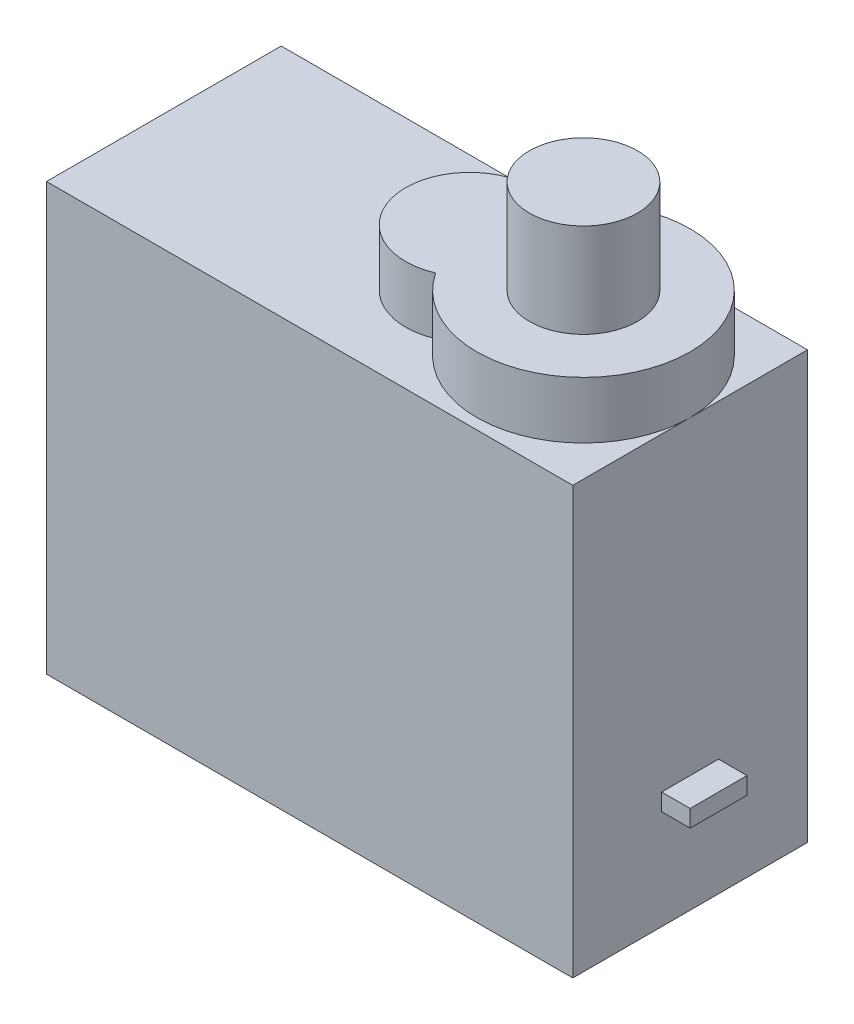
from build123d import *

# Parameters (mm, degrees)
SKETCH_1_W      = 18.5
SKETCH_1_H      = 8.25
EXTRUDE_1_DEPTH = 15
SKETCH_2_R      = 3.75
EXTRUDE_2_DEPTH = 2
SKETCH_3_R      = 2.25
EXTRUDE_3_DEPTH = 2
SKETCH_4_R      = 1.9
EXTRUDE_4_DEPTH = 3.3
SKETCH_5_W      = 2
SKETCH_5_H      = 0.6
EXTRUDE_5_DEPTH = 1


with BuildPart() as part:
    # 草图1 → 凸台-拉伸1 (new body)
    with BuildSketch(Plane(origin=(0, 0, 0), x_dir=(1, 0, 0), z_dir=(0, 1, 0))):
        Rectangle(SKETCH_1_W, SKETCH_1_H)
    extrude(amount=EXTRUDE_1_DEPTH)

    # 草图2 → 凸台-拉伸2 (add)
    with BuildSketch(Plane(origin=(0, 15, 0), x_dir=(1, 0, 0), z_dir=(0, 1, 0))):
        with Locations((5.5, 0)):
            Circle(SKETCH_2_R)
    extrude(amount=EXTRUDE_2_DEPTH)

    # 草图3 → 凸台-拉伸3 (add)
    with BuildSketch(Plane(origin=(0, 15, 0), x_dir=(1, 0, 0), z_dir=(0, 1, 0))):
        with Locations((1.5, 0)):
            Circle(SKETCH_3_R)
    extrude(amount=EXTRUDE_3_DEPTH)

    # 草图4 → 凸台-拉伸4 (add)
    with BuildSketch(Plane(origin=(0, 17, 0), x_dir=(1, 0, 0), z_dir=(0, 1, 0))):
        with Locations((5.5, 0)):
            Circle(SKETCH_4_R)
    extrude(amount=EXTRUDE_4_DEPTH)

    # 草图5 → 凸台-拉伸5 (add)
    with BuildSketch(Plane(origin=(9.25, 0, 0), x_dir=(0, 0, -1), z_dir=(1, 0, 0))):
        with Locations((0, 3.8)):
            Rectangle(SKETCH_5_W, SKETCH_5_H)
    extrude(amount=EXTRUDE_5_DEPTH)


solid = part.part
